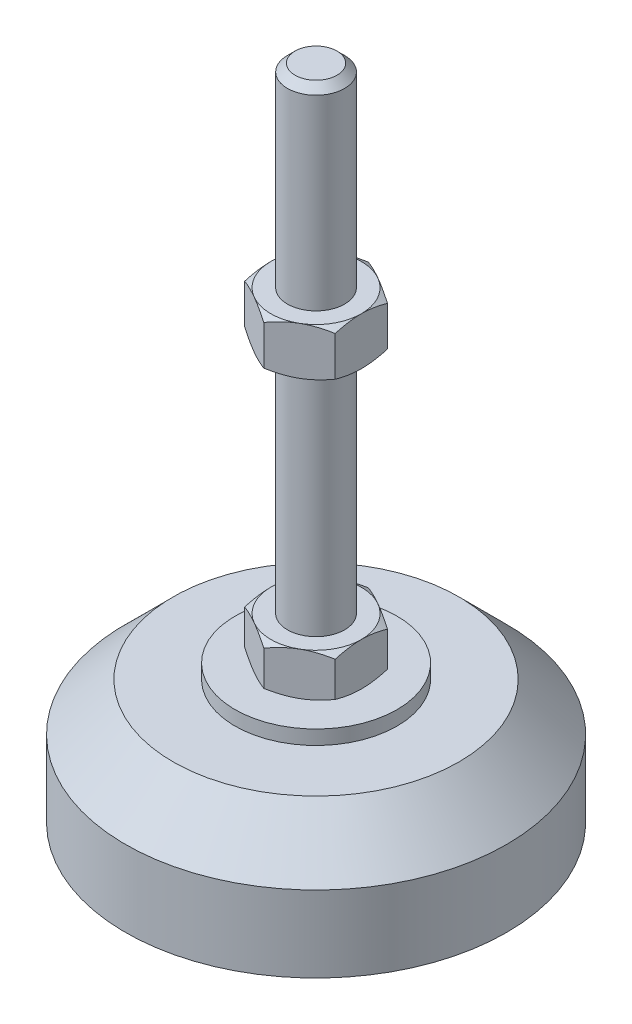
from build123d import *

# Parameters (mm, degrees)
EXTRUDE_1_DEPTH = 9
EXTRUDE_2_DEPTH = 10


with BuildPart() as part:
    # Эскиз1 → Повернуть1 (revolve)
    with BuildSketch(Plane.XY, mode=Mode.PRIVATE) as revolve_1_sk:
        Polygon((0, 0), (-40, 0), (-40, 16), (-30, 26), (-17, 26), (-17, 29), (-6, 29), (-6, 38), (-6, 136.4), (-4.4, 138), (0, 138), align=None)
    revolve(revolve_1_sk.sketch.rotate(Axis((0, 0, 0), (0, 1, 0)), 180), axis=Axis((0, 0, 0), (0, 1, 0)))  # turned: the seam where the file's is

    # Эскиз2 → Бобышка-Вытянуть1 (add)
    with BuildSketch(Plane(origin=(0, 29, 0), x_dir=(1, 0, 0), z_dir=(0, 1, 0))):
        Polygon((0, 10.969655115), (-9.5, 5.484827557), (-9.5, -5.484827557), (0, -10.969655115), (9.5, -5.484827557), (9.5, 5.484827557), align=None)
    extrude(amount=EXTRUDE_1_DEPTH)

    # Эскиз3 → Бобышка-Вытянуть2 (add)
    with BuildSketch(Plane(origin=(0, 87.2, 0), x_dir=(1, 0, 0), z_dir=(0, 1, 0))):
        Polygon((9.5, 5.484827557), (0, 10.969655115), (-9.5, 5.484827557), (-9.5, -5.484827557), (0, -10.969655115), (9.5, -5.484827557), align=None)
    extrude(amount=EXTRUDE_2_DEPTH)

    # Эскиз4 → Вырез-Повернуть2 (revolve, cut)
    with BuildSketch(Plane.XY, mode=Mode.PRIVATE) as cut_revolve_2_sk:
        Polygon((-18.160254038, 97.2), (-9.5, 97.2), (-18.160254038, 92.2), align=None)
        Polygon((-18.160254038, 87.2), (-18.160254038, 92.2), (-9.5, 87.2), align=None)
        Polygon((-17.294228634, 38), (-17.294228634, 33.5), (-9.5, 38), align=None)
        Polygon((-17.294228634, 33.5), (-17.294228634, 29), (-9.5, 29), align=None)
    revolve(cut_revolve_2_sk.sketch.rotate(Axis((0, 138, 0), (0, -1, 0)), 180), axis=Axis((0, 138, 0), (0, -1, 0)), mode=Mode.SUBTRACT)  # turned: the seam where the file's is


solid = part.part
